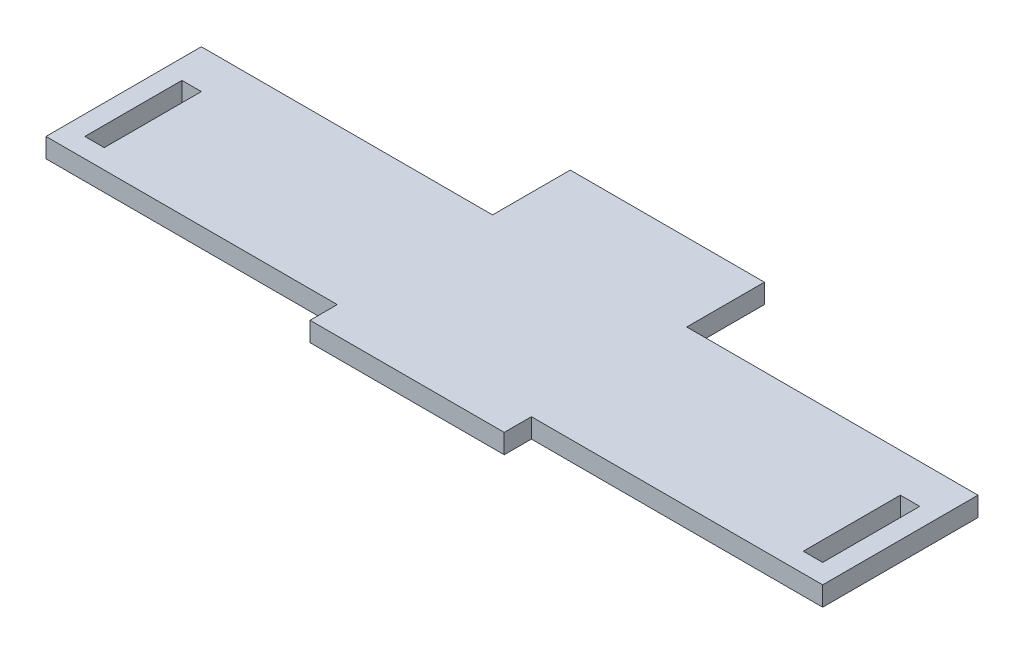
from build123d import *

# Parameters (mm, degrees)
SKETCH1_W           = 5
SKETCH1_H           = 25
BOSS_EXTRUDE1_DEPTH = 5


with BuildPart() as part:
    # Sketch1 → Boss-Extrude1 (new body)
    with BuildSketch(Plane(origin=(0, 0, 0), x_dir=(1, 0, 0), z_dir=(0, 1, 0))):
        Polygon((-25, 28.75), (-100, 28.75), (-100, -11.25), (-25, -11.25), (-25, -18.25), (25, -18.25), (25, -11.25), (100, -11.25), (100, 28.75), (25, 28.75), (25, 48.75), (-25, 48.75), align=None)
        with Locations((92.5, 6.25)):
            Rectangle(SKETCH1_W, SKETCH1_H, mode=Mode.SUBTRACT)
        with Locations((-92.5, 6.25)):
            Rectangle(SKETCH1_W, SKETCH1_H, mode=Mode.SUBTRACT)
    extrude(amount=BOSS_EXTRUDE1_DEPTH)


solid = part.part
